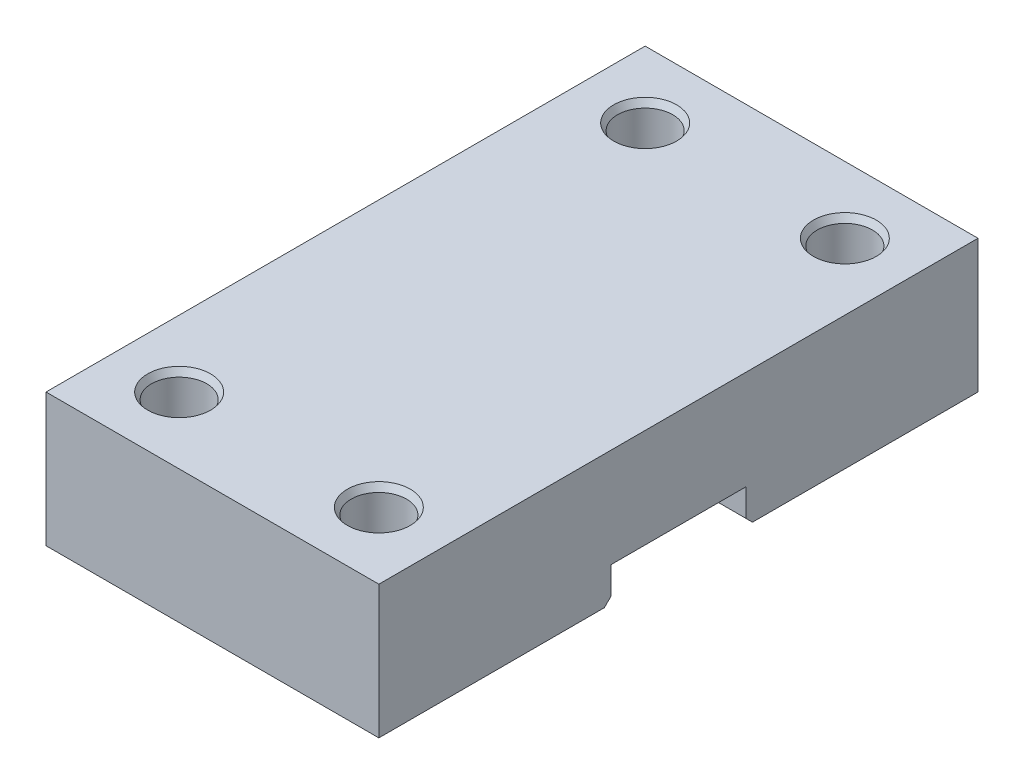
from build123d import *

# Parameters (mm, degrees)
SKETCH1_W               = 50
SKETCH1_H               = 90
BOSS_EXTRUDE1_DEPTH     = 20
SKETCH2_W               = 20.25
SKETCH2_H               = 5.1
CUT_EXTRUDE1_DEPTH      = 1
CUT_EXTRUDE1_DEPTH_BACK = 51
SKETCH3_R               = 4.15
CUT_EXTRUDE2_DEPTH      = 21
CHAMFER1_SIZE           = 1
CHAMFER1_SIZE2          = 0.577350269
CHAMFER1_PART_2_SIZE    = 1
CHAMFER1_PART_2_SIZE2   = 0.577350269
CHAMFER1_PART_3_SIZE    = 1
CHAMFER1_PART_3_SIZE2   = 0.577350269
CHAMFER1_PART_4_SIZE    = 1
CHAMFER1_PART_4_SIZE2   = 0.577350269
CHAMFER2_SIZE           = 1


with BuildPart() as part:
    # Sketch1 → Boss-Extrude1 (new body)
    with BuildSketch(Plane(origin=(0, 0, 0), x_dir=(1, 0, 0), z_dir=(0, 1, 0))):
        Rectangle(SKETCH1_W, SKETCH1_H)
    extrude(amount=BOSS_EXTRUDE1_DEPTH)

    # Sketch2 → Cut-Extrude1 (cut, two sides)
    with BuildSketch(Plane(origin=(25, 0, 0), x_dir=(0, 0, -1), z_dir=(1, 0, 0))) as cut_extrude1_sk:
        with Locations((0, 2.55)):
            Rectangle(SKETCH2_W, SKETCH2_H)
    extrude(amount=CUT_EXTRUDE1_DEPTH, mode=Mode.SUBTRACT)
    extrude(cut_extrude1_sk.sketch, amount=-CUT_EXTRUDE1_DEPTH_BACK, mode=Mode.SUBTRACT)

    # Sketch3 → Cut-Extrude2 (cut, through all)
    with BuildSketch(Plane.XZ):
        with Locations(Location((-15, 35, 0), (0, 0, 270))):  # turned: the seam where the file's is
            Circle(SKETCH3_R)
        with Locations(Location((-15, -35, 0), (0, 0, 270))):  # turned: the seam where the file's is
            Circle(SKETCH3_R)
        with Locations(Location((15, 35, 0), (0, 0, 270))):  # turned: the seam where the file's is
            Circle(SKETCH3_R)
        with Locations(Location((15, -35, 0), (0, 0, 270))):  # turned: the seam where the file's is
            Circle(SKETCH3_R)
    extrude(amount=-CUT_EXTRUDE2_DEPTH, mode=Mode.SUBTRACT)

    # Chamfer1
    chamfer1_edges = [part.edges().sort_by_distance(p)[0] for p in [
        (-15, 20, 39.15),
    ]]
    chamfer1_side = [part.faces().sort_by_distance(p)[0] for p in [
        (-15, 10, 39.15),
    ]]
    chamfer(chamfer1_edges, length=CHAMFER1_SIZE, length2=CHAMFER1_SIZE2, reference=chamfer1_side[0])

    # Chamfer1 part 2
    chamfer1_part_2_edges = [part.edges().sort_by_distance(p)[0] for p in [
        (15, 20, 39.15),
    ]]
    chamfer1_part_2_side = [part.faces().sort_by_distance(p)[0] for p in [
        (15, 10, 39.15),
    ]]
    chamfer(chamfer1_part_2_edges, length=CHAMFER1_PART_2_SIZE, length2=CHAMFER1_PART_2_SIZE2, reference=chamfer1_part_2_side[0])

    # Chamfer1 part 3
    chamfer1_part_3_edges = [part.edges().sort_by_distance(p)[0] for p in [
        (15, 20, -30.85),
    ]]
    chamfer1_part_3_side = [part.faces().sort_by_distance(p)[0] for p in [
        (15, 10, -30.85),
    ]]
    chamfer(chamfer1_part_3_edges, length=CHAMFER1_PART_3_SIZE, length2=CHAMFER1_PART_3_SIZE2, reference=chamfer1_part_3_side[0])

    # Chamfer1 part 4
    chamfer1_part_4_edges = [part.edges().sort_by_distance(p)[0] for p in [
        (-15, 20, -30.85),
    ]]
    chamfer1_part_4_side = [part.faces().sort_by_distance(p)[0] for p in [
        (-15, 10, -30.85),
    ]]
    chamfer(chamfer1_part_4_edges, length=CHAMFER1_PART_4_SIZE, length2=CHAMFER1_PART_4_SIZE2, reference=chamfer1_part_4_side[0])

    # Chamfer2
    chamfer2_edges = [part.edges().sort_by_distance(p)[0] for p in [
        (0, 0, -10.125),
        (0, 0, 10.125),
    ]]
    chamfer(chamfer2_edges, length=CHAMFER2_SIZE)


solid = part.part
